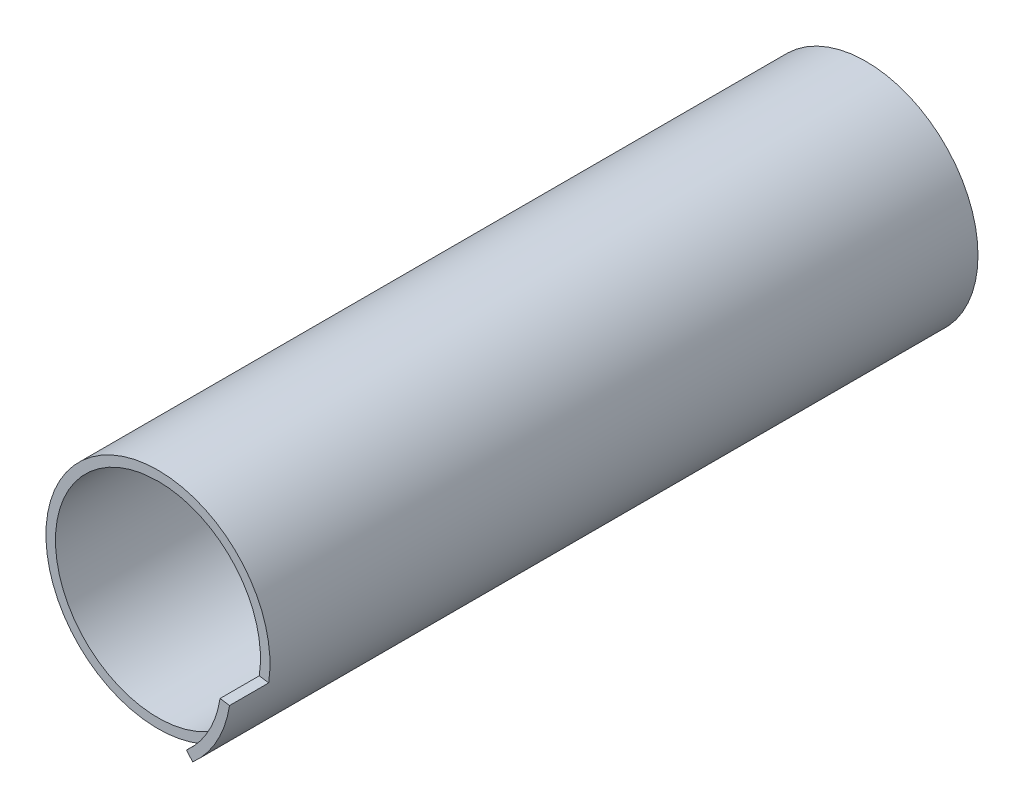
from build123d import *

# Parameters (mm, degrees)
SKETCH_2_R          = 20
SKETCH_2_R_2        = 18.3
EXTRUDE_1_DEPTH     = 126.4
SKETCH_5_R          = 3
EXTRUDE_3_DEPTH     = 126.4
CUT_EXTRUDE1_DEPTH  = 59
CUT_EXTRUDE2_DEPTH  = 59
BOSS_EXTRUDE4_DEPTH = 7
SKETCH3_R           = 3
BOSS_EXTRUDE6_DEPTH = 58.6


with BuildPart() as part:
    # Эскиз2 → Бобышка-Вытянуть1 (new body)
    with BuildSketch(Plane.XY):
        Circle(SKETCH_2_R)
        Circle(SKETCH_2_R_2, mode=Mode.SUBTRACT)
    extrude(amount=EXTRUDE_1_DEPTH)

    # Эскиз5 → Бобышка-Вытянуть3 (add, through all)
    with BuildSketch(Plane(origin=(0, 0, 0), x_dir=(-1, 0, 0), z_dir=(0, 0, -1))):
        with BuildLine():
            Line((0, 18.3), (0, 9.219544457))
            ThreePointArc((0, 9.219544457), (-0.725705562, 6.35915669), (-2.727272727, 4.190702026))
            ThreePointArc((-2.727272727, 4.190702026), (-0.409836066, -4.983175132), (3.375314281, 3.688801093))
            ThreePointArc((3.375314281, 3.688801093), (1.754930846, 6.155139323), (1.506314907, 9.095659151))
            Line((1.506314907, 9.095659151), (2.989905079, 18.054098361))
            ThreePointArc((2.989905079, 18.054098361), (1.5, 18.238420984), (0, 18.3))
        make_face()
        Circle(SKETCH_5_R, mode=Mode.SUBTRACT)
    extrude(amount=-EXTRUDE_3_DEPTH)

    # Sketch1 → Cut-Extrude1 (cut)
    with BuildSketch(Plane(origin=(0, 0, 0), x_dir=(-1, 0, 0), z_dir=(0, 0, -1))):
        with BuildLine():
            Line((0, 18.3), (2.989905079, 18.054098361))
            ThreePointArc((2.989905079, 18.054098361), (-1.5, -18.238420984), (0, 18.3))
        make_face()
    extrude(amount=-CUT_EXTRUDE1_DEPTH, mode=Mode.SUBTRACT)

    # Sketch2 → Cut-Extrude2 (cut)
    with BuildSketch(Plane.XY.offset(126.4)):
        with BuildLine():
            Line((0, 18.3), (-2.989905079, 18.054098361))
            ThreePointArc((-2.989905079, 18.054098361), (1.5, -18.238420984), (0, 18.3))
        make_face()
    extrude(amount=-CUT_EXTRUDE2_DEPTH, mode=Mode.SUBTRACT)

    # Sketch6 → Boss-Extrude4 (add)
    with BuildSketch(Plane.XY.offset(126.4)):
        with BuildLine():
            Line((19.770932531, -3.018315232), (18.090403266, -2.761758437))
            ThreePointArc((18.090403266, -2.761758437), (16.05484144, -8.782486342), (12.082828792, -13.743916778))
            Line((12.082828792, -13.743916778), (13.205277368, -15.020674074))
            ThreePointArc((13.205277368, -15.020674074), (17.546274798, -9.598345728), (19.770932531, -3.018315232))
        make_face()
    extrude(amount=BOSS_EXTRUDE4_DEPTH)


with BuildPart() as body_2:
    # Sketch3 → Boss-Extrude6 (new body)
    with BuildSketch(Plane.XY):
        with BuildLine():
            Line((5, 0), (5, 16.561702811))
            ThreePointArc((5, 16.561702811), (0, 17.3), (-5, 16.561702811))
            Line((-5, 16.561702811), (-5, 0))
            ThreePointArc((-5, 0), (0, -5), (5, 0))
        make_face()
        Circle(SKETCH3_R, mode=Mode.SUBTRACT)
    extrude(amount=BOSS_EXTRUDE6_DEPTH)


solid = Compound([part.part, body_2.part])
